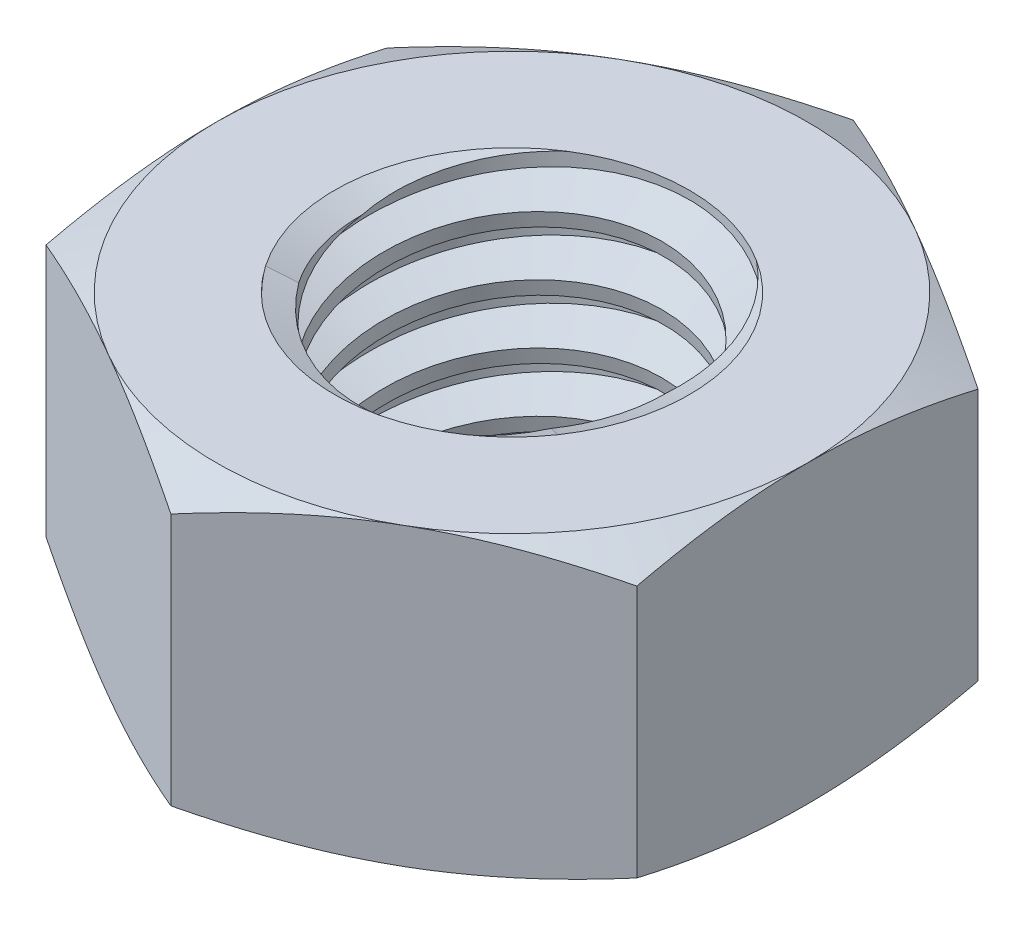
from build123d import *

# Parameters (mm, degrees)
EXTRUDE1_DEPTH      = 2.5
SKETCH2_W           = 3
SKETCH2_H           = 5
LPATTERN1_COUNT     = 5
LPATTERN1_PITCH     = 1
LPATTERN1_COL_COUNT = 2
LPATTERN1_COL_PITCH = 1


with BuildPart() as part:
    # Sketch1 → Extrude1 (new body, symmetric)
    with BuildSketch(Plane(origin=(0, 0, 0), x_dir=(1, 0, 0), z_dir=(0, 1, 0))):
        Polygon((0, 5.773502692), (-5, 2.886751346), (-5, -2.886751346), (0, -5.773502692), (5, -2.886751346), (5, 2.886751346), align=None)
    extrude(amount=EXTRUDE1_DEPTH, both=True)

    # Sketch4 → Cut-Revolve2 (revolve, cut)
    with BuildSketch(Plane(origin=(0, 0, 0), x_dir=(0, 0, -1), z_dir=(1, 0, 0))):
        Polygon((0, 2.5), (3, 2.5), (2.538023184, 2.284576673), (2.538023184, -2.284576673), (3, -2.5), (0, -2.5), align=None)
    revolve(axis=Axis((0, 2.5, 0), (0, 1, 0)), mode=Mode.SUBTRACT)


with BuildPart() as body_2:
    # Sketch2 → Revolve1 (revolve)
    with BuildSketch(Plane(origin=(0, 0, 0), x_dir=(0, 0, -1), z_dir=(1, 0, 0))):
        with Locations((1.5, 0)):
            Rectangle(SKETCH2_W, SKETCH2_H)
    revolve(axis=Axis((0, -5.5, 0), (0, 1, 0)))

    # Sketch3 → Cut-Revolve1 (revolve, cut)
    with BuildSketch(Plane(origin=(0, 0, 0), x_dir=(0, 0, -1), z_dir=(1, 0, 0))):
        Polygon((3.020549873, 2.37670076), (3.164398987, 1.513606076), (2.579122931, 1.732870615), (2.538023184, 1.979469096), align=None)
    cut_revolve1 = revolve(axis=Axis((0, 2.5, 0.178376498), (0, -0.986393924, -0.164398987)), mode=Mode.SUBTRACT)

    # LPattern1: Cut-Revolve1 ×5
    with Locations(*[(0, -i * LPATTERN1_PITCH, 0) for i in range(1, LPATTERN1_COUNT)]):
        add(cut_revolve1, mode=Mode.SUBTRACT)

    # LPattern1 col: Cut-Revolve1 ×2
    with Locations(*[(0, i * LPATTERN1_COL_PITCH, 0) for i in range(1, LPATTERN1_COL_COUNT)]):
        add(cut_revolve1, mode=Mode.SUBTRACT)


with BuildPart() as part_1:
    add(part.part)

    # Combine1: cut body 2
    add(body_2.part, mode=Mode.SUBTRACT)

    # Sketch5 → Cut-Revolve3 (revolve, cut)
    with BuildSketch(Plane(origin=(0, 0, 0), x_dir=(0, 0, -1), z_dir=(1, 0, 0))):
        Polygon((0, -2.5), (5, -2.5), (5.773502692, -2.139309771), (5.773502692, 2.139309771), (5, 2.5), (0, 2.5), (0, 3.77), (7.043502692, 3.77), (7.043502692, -3.77), (0, -3.77), align=None)
    revolve(axis=Axis((0, -2.5, 0), (0, 1, 0)), mode=Mode.SUBTRACT)


solid = part_1.part
